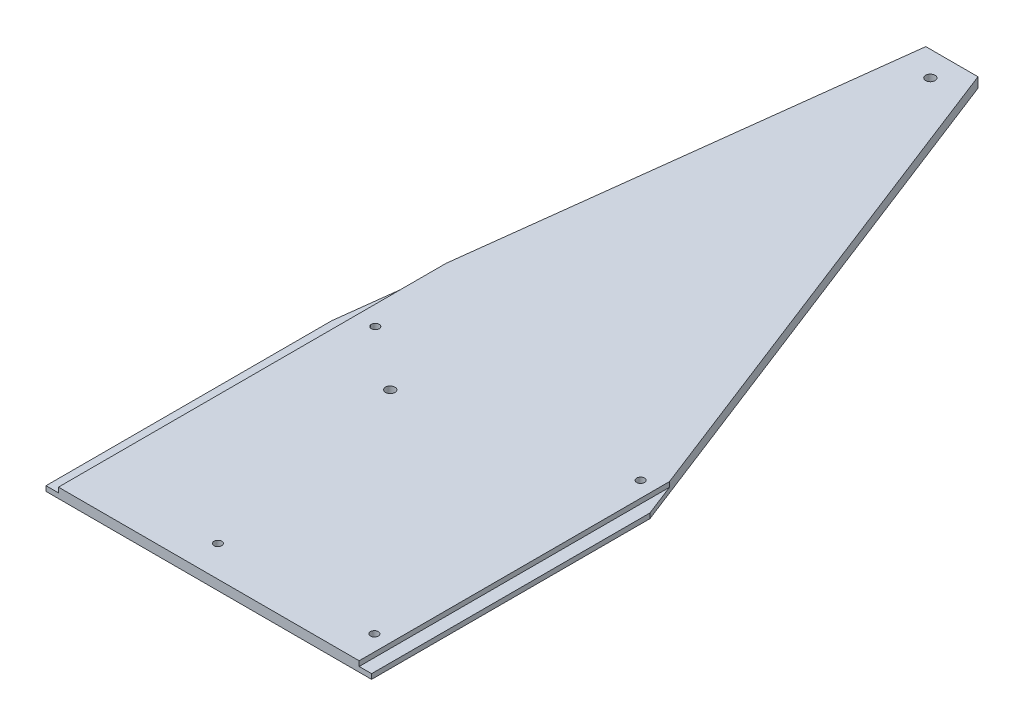
from build123d import *

# Parameters (mm, degrees)
SKETCH2_R               = 3
SKETCH2_R_2             = 2.5
BOSS_EXTRUDE1_DEPTH     = 6.35
SKETCH3_W               = 7.9375
SKETCH3_H               = 3.175
CUT_EXTRUDE1_DEPTH      = 1
CUT_EXTRUDE1_DEPTH_BACK = 521.7


with BuildPart() as part:
    # Sketch2 → Boss-Extrude1 (new body)
    with BuildSketch(Plane(origin=(0, 0, 0), x_dir=(1, 0, 0), z_dir=(0, 1, 0))):
        Polygon((0, 0), (0, 182.5625), (41.275, 520.7), (74.6125, 520.7), (207.9625, 177.8), (207.9625, 0), align=None)
        with Locations((60.061658842, 504.825)):
            Circle(SKETCH2_R, mode=Mode.SUBTRACT)
        with Locations((20.301658842, 190.035)):
            Circle(SKETCH2_R_2, mode=Mode.SUBTRACT)
        with Locations((190.081658842, 189.735)):
            Circle(SKETCH2_R_2, mode=Mode.SUBTRACT)
        with Locations((190.001658842, 19.755)):
            Circle(SKETCH2_R_2, mode=Mode.SUBTRACT)
        with Locations((90.031658842, 19.755)):
            Circle(SKETCH2_R_2, mode=Mode.SUBTRACT)
        with Locations((60.061658842, 159.795)):
            Circle(SKETCH2_R, mode=Mode.SUBTRACT)
    extrude(amount=BOSS_EXTRUDE1_DEPTH)

    # Sketch3 → Cut-Extrude1 (cut, two sides)
    with BuildSketch(Plane.XY) as cut_extrude1_sk:
        with Locations((3.96875, 4.7625)):
            Rectangle(SKETCH3_W, SKETCH3_H)
        with Locations((203.99375, 4.7625)):
            Rectangle(SKETCH3_W, SKETCH3_H)
    extrude(amount=CUT_EXTRUDE1_DEPTH, mode=Mode.SUBTRACT)
    extrude(cut_extrude1_sk.sketch, amount=-CUT_EXTRUDE1_DEPTH_BACK, mode=Mode.SUBTRACT)


solid = part.part
